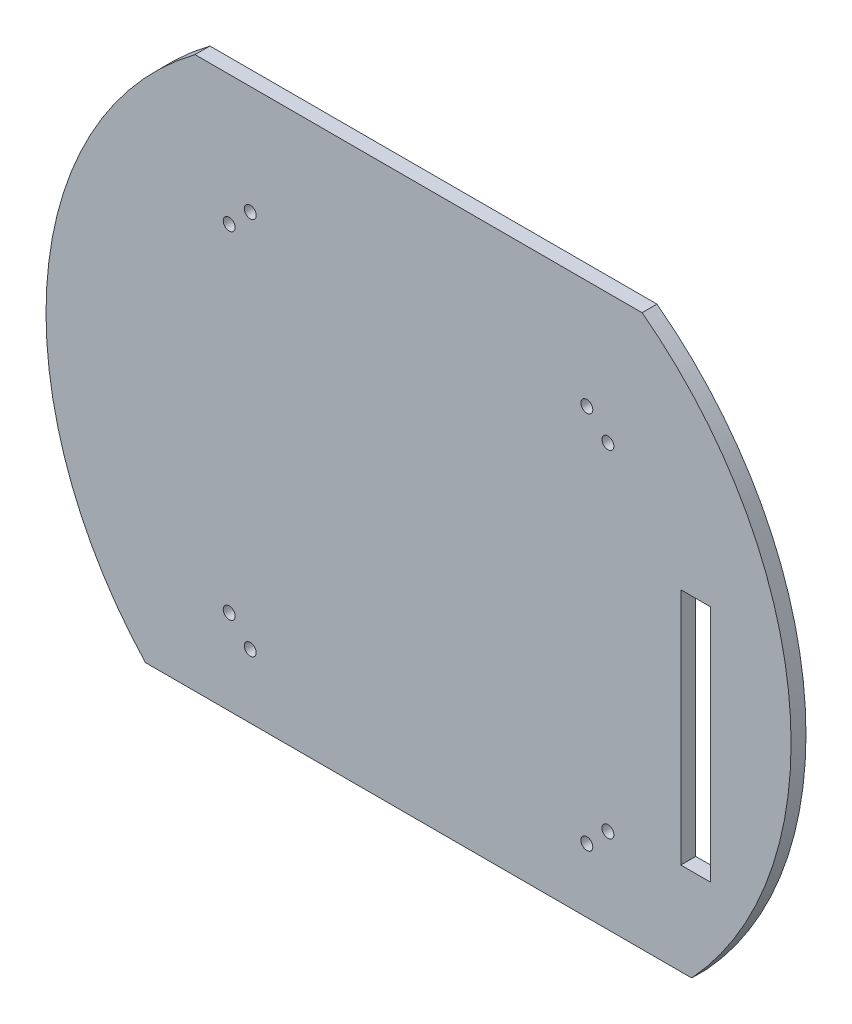
from build123d import *

# Parameters (mm, degrees)
SKETCH1_R           = 125
BOSS_EXTRUDE1_DEPTH = 5
CUT_EXTRUDE1_REACH  = 7
SKETCH2_R           = 2
CUT_EXTRUDE2_REACH  = 7
CUT_EXTRUDE3_REACH  = 7
SKETCH4_W           = 10
SKETCH4_H           = 80
CUT_EXTRUDE4_REACH  = 7


with BuildPart() as part:
    # Sketch1 → Boss-Extrude1 (new body)
    with BuildSketch(Plane.XY):
        Circle(SKETCH1_R)
    extrude(amount=BOSS_EXTRUDE1_DEPTH)

    # Sketch2 → Cut-Extrude1 (cut, up to next)
    with BuildSketch(Plane.XY.offset(5), mode=Mode.PRIVATE) as cut_extrude1_sk1:
        with Locations((-56.464466094, -63.535533906)):
            Circle(SKETCH2_R)
    cut_extrude1_tool1 = extrude(cut_extrude1_sk1.sketch, amount=-CUT_EXTRUDE1_REACH, mode=Mode.PRIVATE) & part.part
    add(cut_extrude1_tool1.solids().sort_by_distance((-56.464466, -63.535534, 5))[0], mode=Mode.SUBTRACT)
    # Sketch2 → Cut-Extrude1 (cut, up to next)
    with BuildSketch(Plane.XY.offset(5), mode=Mode.PRIVATE) as cut_extrude1_sk2:
        with Locations((-63.535533906, -56.464466094)):
            Circle(SKETCH2_R)
    cut_extrude1_tool2 = extrude(cut_extrude1_sk2.sketch, amount=-CUT_EXTRUDE1_REACH, mode=Mode.PRIVATE) & part.part
    add(cut_extrude1_tool2.solids().sort_by_distance((-63.535534, -56.464466, 5))[0], mode=Mode.SUBTRACT)
    # Sketch2 → Cut-Extrude1 (cut, up to next)
    with BuildSketch(Plane.XY.offset(5), mode=Mode.PRIVATE) as cut_extrude1_sk3:
        with Locations((-56.464466094, 63.535533906)):
            Circle(SKETCH2_R)
    cut_extrude1_tool3 = extrude(cut_extrude1_sk3.sketch, amount=-CUT_EXTRUDE1_REACH, mode=Mode.PRIVATE) & part.part
    add(cut_extrude1_tool3.solids().sort_by_distance((-56.464466, 63.535534, 5))[0], mode=Mode.SUBTRACT)
    # Sketch2 → Cut-Extrude1 (cut, up to next)
    with BuildSketch(Plane.XY.offset(5), mode=Mode.PRIVATE) as cut_extrude1_sk4:
        with Locations((-63.535533906, 56.464466094)):
            Circle(SKETCH2_R)
    cut_extrude1_tool4 = extrude(cut_extrude1_sk4.sketch, amount=-CUT_EXTRUDE1_REACH, mode=Mode.PRIVATE) & part.part
    add(cut_extrude1_tool4.solids().sort_by_distance((-63.535534, 56.464466, 5))[0], mode=Mode.SUBTRACT)
    # Sketch2 → Cut-Extrude1 (cut, up to next)
    with BuildSketch(Plane.XY.offset(5), mode=Mode.PRIVATE) as cut_extrude1_sk5:
        with Locations((56.464466094, 63.535533906)):
            Circle(SKETCH2_R)
    cut_extrude1_tool5 = extrude(cut_extrude1_sk5.sketch, amount=-CUT_EXTRUDE1_REACH, mode=Mode.PRIVATE) & part.part
    add(cut_extrude1_tool5.solids().sort_by_distance((56.464466, 63.535534, 5))[0], mode=Mode.SUBTRACT)
    # Sketch2 → Cut-Extrude1 (cut, up to next)
    with BuildSketch(Plane.XY.offset(5), mode=Mode.PRIVATE) as cut_extrude1_sk6:
        with Locations((63.535533906, 56.464466094)):
            Circle(SKETCH2_R)
    cut_extrude1_tool6 = extrude(cut_extrude1_sk6.sketch, amount=-CUT_EXTRUDE1_REACH, mode=Mode.PRIVATE) & part.part
    add(cut_extrude1_tool6.solids().sort_by_distance((63.535534, 56.464466, 5))[0], mode=Mode.SUBTRACT)
    # Sketch2 → Cut-Extrude1 (cut, up to next)
    with BuildSketch(Plane.XY.offset(5), mode=Mode.PRIVATE) as cut_extrude1_sk7:
        with Locations((63.535533906, -56.464466094)):
            Circle(SKETCH2_R)
    cut_extrude1_tool7 = extrude(cut_extrude1_sk7.sketch, amount=-CUT_EXTRUDE1_REACH, mode=Mode.PRIVATE) & part.part
    add(cut_extrude1_tool7.solids().sort_by_distance((63.535534, -56.464466, 5))[0], mode=Mode.SUBTRACT)
    # Sketch2 → Cut-Extrude1 (cut, up to next)
    with BuildSketch(Plane.XY.offset(5), mode=Mode.PRIVATE) as cut_extrude1_sk8:
        with Locations((56.464466094, -63.535533906)):
            Circle(SKETCH2_R)
    cut_extrude1_tool8 = extrude(cut_extrude1_sk8.sketch, amount=-CUT_EXTRUDE1_REACH, mode=Mode.PRIVATE) & part.part
    add(cut_extrude1_tool8.solids().sort_by_distance((56.464466, -63.535534, 5))[0], mode=Mode.SUBTRACT)

    # Sketch3 → Cut-Extrude2 (cut, up to next)
    with BuildSketch(Plane.XY.offset(5), mode=Mode.PRIVATE) as cut_extrude2_sk1:
        with BuildLine():
            Line((-91.651513899, -85), (91.651513899, -85))
            ThreePointArc((91.651513899, -85), (0, -125), (-91.651513899, -85))
        make_face()
    cut_extrude2_tool1 = extrude(cut_extrude2_sk1.sketch, amount=-CUT_EXTRUDE2_REACH, mode=Mode.PRIVATE) & part.part
    add(cut_extrude2_tool1.solids().sort_by_distance((0, -101.241971, 5))[0], mode=Mode.SUBTRACT)

    # Sketch4 → Cut-Extrude3 (cut, up to next)
    with BuildSketch(Plane.XY.offset(5), mode=Mode.PRIVATE) as cut_extrude3_sk1:
        with Locations((93, -14)):
            Rectangle(SKETCH4_W, SKETCH4_H)
    cut_extrude3_tool1 = extrude(cut_extrude3_sk1.sketch, amount=-CUT_EXTRUDE3_REACH, mode=Mode.PRIVATE) & part.part
    add(cut_extrude3_tool1.solids().sort_by_distance((93, -14, 5))[0], mode=Mode.SUBTRACT)

    # Sketch5 → Cut-Extrude4 (cut, up to next)
    with BuildSketch(Plane.XY.offset(5), mode=Mode.PRIVATE) as cut_extrude4_sk1:
        with BuildLine():
            ThreePointArc((75, 100), (0, 125), (-75, 100))
            Line((-75, 100), (75, 100))
        make_face()
    cut_extrude4_tool1 = extrude(cut_extrude4_sk1.sketch, amount=-CUT_EXTRUDE4_REACH, mode=Mode.PRIVATE) & part.part
    add(cut_extrude4_tool1.solids().sort_by_distance((0, 110.090997, 5))[0], mode=Mode.SUBTRACT)


solid = part.part
